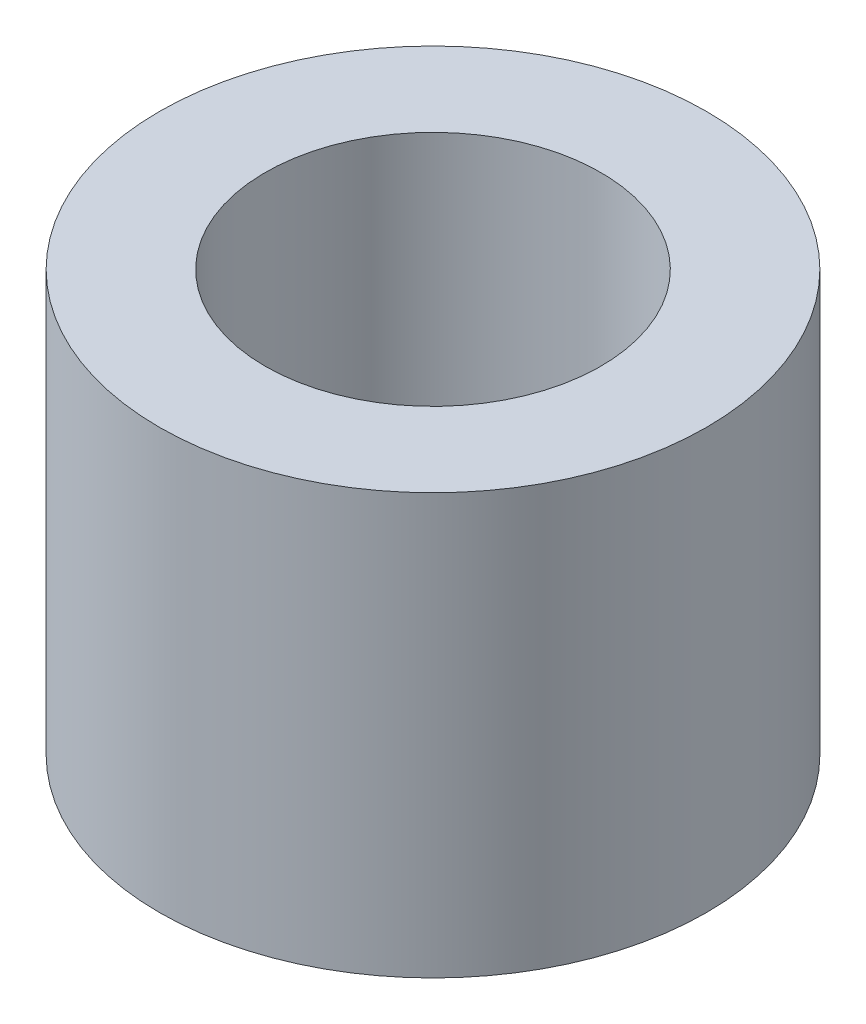
from build123d import *

# Parameters (mm, degrees)
SKETCH1_R           = 5.17525
SKETCH1_R_2         = 3.175
BOSS_EXTRUDE1_DEPTH = 7.9502


with BuildPart() as part:
    # Sketch1 → Boss-Extrude1 (new body)
    with BuildSketch(Plane(origin=(0, 0, 0), x_dir=(1, 0, 0), z_dir=(0, 1, 0))):
        Circle(SKETCH1_R)
        Circle(SKETCH1_R_2, mode=Mode.SUBTRACT)
    extrude(amount=BOSS_EXTRUDE1_DEPTH)


solid = part.part
